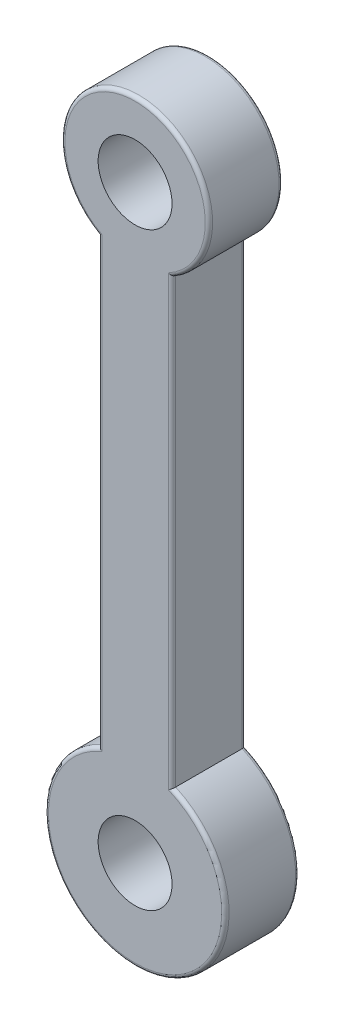
from build123d import *

# Parameters (mm, degrees)
ESQUISSE1_R        = 10
BOSS_EXTRU_1_DEPTH = 20
CONG_2_R           = 1


with BuildPart() as part:
    # Esquisse1 → Boss.-Extru.1 (new body)
    with BuildSketch(Plane.XY):
        with BuildLine():
            Line((-10, -17.320508076), (-10, -137.320508076))
            ThreePointArc((-10, -137.320508076), (0, -184.099247501), (10, -137.320508076))
            Line((10, -137.320508076), (10, -17.320508076))
            ThreePointArc((10, -17.320508076), (0, 20), (-10, -17.320508076))
        make_face()
        Circle(ESQUISSE1_R, mode=Mode.SUBTRACT)
        with Locations((0, -159.641016151)):
            Circle(ESQUISSE1_R, mode=Mode.SUBTRACT)
    extrude(amount=BOSS_EXTRU_1_DEPTH)

    # Congé2
    cong_2_edges = [part.edges().sort_by_distance(p)[0] for p in [
        (0, -184.099247501, 20),
        (10, -77.320508076, 20),
        (0, 20, 20),
        (10, -77.320508076, 0),
        (0, -184.099247501, 0),
        (-10, -77.320508076, 0),
        (0, 20, 0),
        (-10, -77.320508076, 20),
    ]]
    fillet(cong_2_edges, radius=CONG_2_R)


solid = part.part
